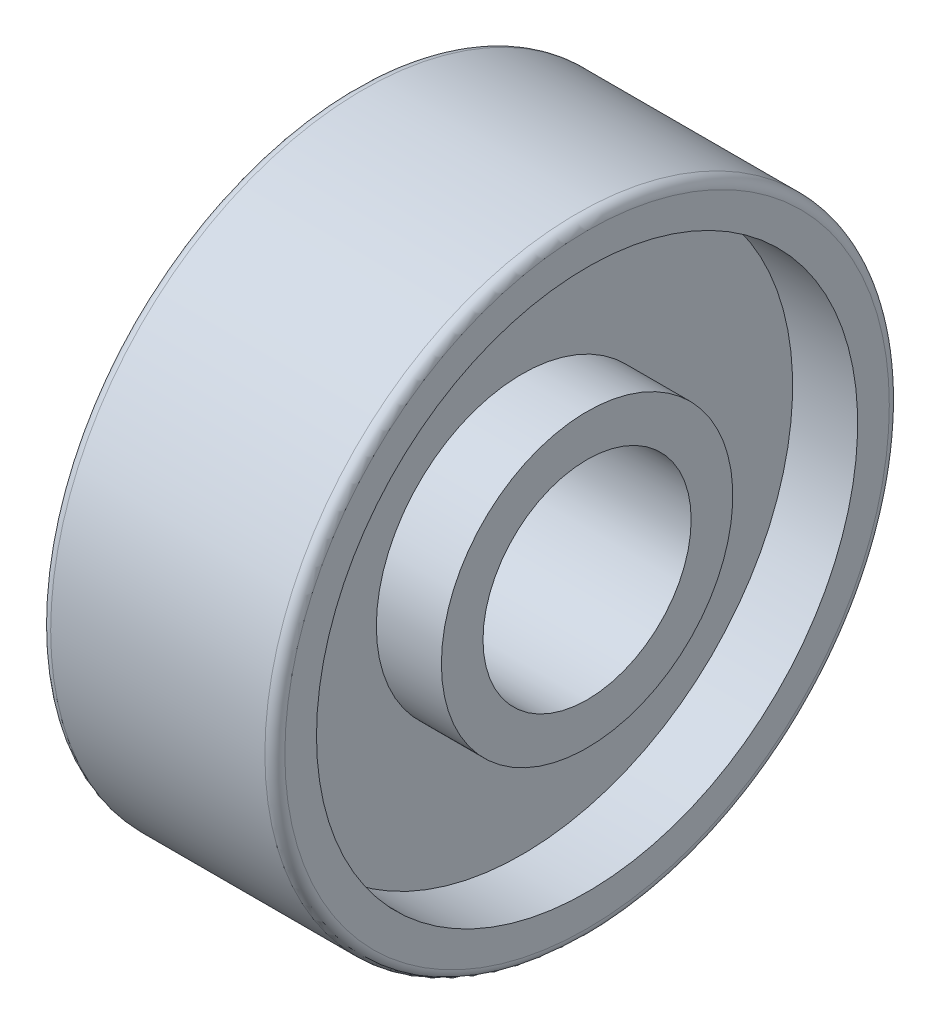
from build123d import *


with BuildPart() as part:
    # Sketch3 → bearing-revolution (revolve)
    with BuildSketch(Plane.XY):
        with BuildLine():
            Line((0.3048, 3.175), (7.14375, 3.175))
            Line((7.14375, 3.175), (7.14375, 4.445))
            Line((7.14375, 4.445), (5.159375, 4.445))
            Line((5.159375, 4.445), (5.159375, 8.255))
            Line((5.159375, 8.255), (7.14375, 8.255))
            Line((7.14375, 8.255), (7.14375, 9.2202))
            ThreePointArc((7.14375, 9.2202), (7.054476147, 9.435726147), (6.83895, 9.525))
            Line((6.83895, 9.525), (0.3048, 9.525))
            ThreePointArc((0.3048, 9.525), (0.089273853, 9.435726147), (0, 9.2202))
            Line((0, 9.2202), (0, 8.255))
            Line((0, 8.255), (1.984375, 8.255))
            Line((1.984375, 8.255), (1.984375, 4.445))
            Line((1.984375, 4.445), (0, 4.445))
            Line((0, 4.445), (0, 3.4798))
            ThreePointArc((0, 3.4798), (0.089273853, 3.264273853), (0.3048, 3.175))
        make_face()
    revolve(axis=Axis((-4.832058368, 0, 0), (1, 0, 0)))


solid = part.part
